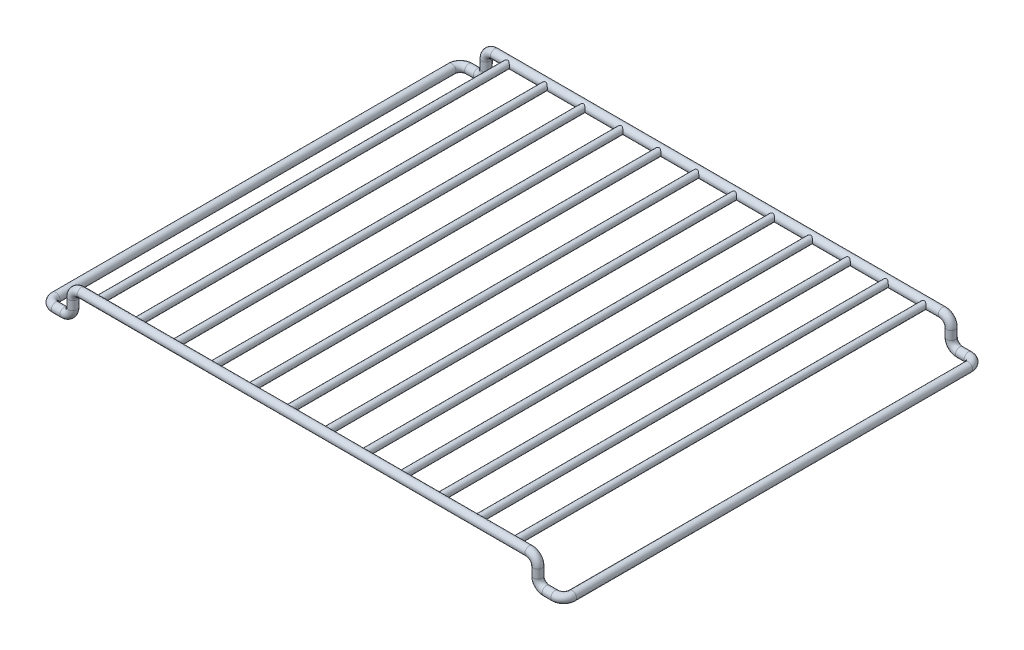
from build123d import *

# Parameters (mm, degrees)
SKETCH1_R                = 2.5
BOSS_EXTRUDE1_REACH      = 289
BOSS_EXTRUDE1_END_RADIUS = 2.5
SKETCH2_R                = 2
LPATTERN1_COUNT          = 6
LPATTERN1_PITCH          = 22


with BuildPart() as part:
    # Sweep1: sweep along a curve in space
    with BuildLine() as sweep1_path:
        Line((0, 0, 0), (130, 0, 0))
        ThreePointArc((130, 0, 0), (133.535533906, -1.464466094, 0), (135, -5, 0))
        Line((135, -5, 0), (135, -10, 0))
        ThreePointArc((140, -15, 0), (136.464466094, -13.535533906, 0), (135, -10, 0))
        Line((140, -15, 0), (145, -15, 0))
        ThreePointArc((145, -15, 0), (148.535533906, -15, -1.464466094), (150, -15, -5))
        Line((150, -15, -5), (150, -15, -235))
        ThreePointArc((150, -15, -235), (148.535533906, -15, -238.535533906), (145, -15, -240))
        Line((145, -15, -240), (140, -15, -240))
        ThreePointArc((135, -10, -240), (136.464466094, -13.535533906, -240), (140, -15, -240))
        Line((135, -10, -240), (135, -5, -240))
        ThreePointArc((135, -5, -240), (133.535533906, -1.464466094, -240), (130, 0, -240))
        Line((130, 0, -240), (0, 0, -240))
    # Sketch1 → Sweep1 (sweep)
    with BuildSketch(Plane(origin=(0, 0, 0), x_dir=(0, 0, -1), z_dir=(1, 0, 0))):
        Circle(SKETCH1_R)
    sweep(path=sweep1_path.line)

    # Boss-Extrude1: up to this cylinder (the profile starts outside it)
    boss_extrude1_end = Plane(origin=(11, 0, -240), z_dir=(-1, 0, 0)) * Cylinder(BOSS_EXTRUDE1_END_RADIUS, 584, mode=Mode.PRIVATE)
    # Sketch2 → Boss-Extrude1 (add, up to the surface)
    with BuildSketch(Plane.XY, mode=Mode.PRIVATE) as boss_extrude1_sk1:
        with Locations((11, 0)):
            Circle(SKETCH2_R)
    boss_extrude1_tool1 = extrude(boss_extrude1_sk1.sketch, amount=-BOSS_EXTRUDE1_REACH, mode=Mode.PRIVATE) - boss_extrude1_end
    boss_extrude1 = boss_extrude1_tool1.solids().sort_by_distance((11, 0, 0))[0]
    add(boss_extrude1)

    # LPattern1: Boss-Extrude1 ×6
    with Locations(*[(i * LPATTERN1_PITCH, 0, 0) for i in range(1, LPATTERN1_COUNT)]):
        add(boss_extrude1)

    # Mirror1: part across plane


with BuildPart() as part_1:
    add(part.part)
    add(part.part.mirror(Plane(origin=(0, 0, 0), x_dir=(0, 0, 1), z_dir=(1, 0, 0))))


solid = part_1.part
